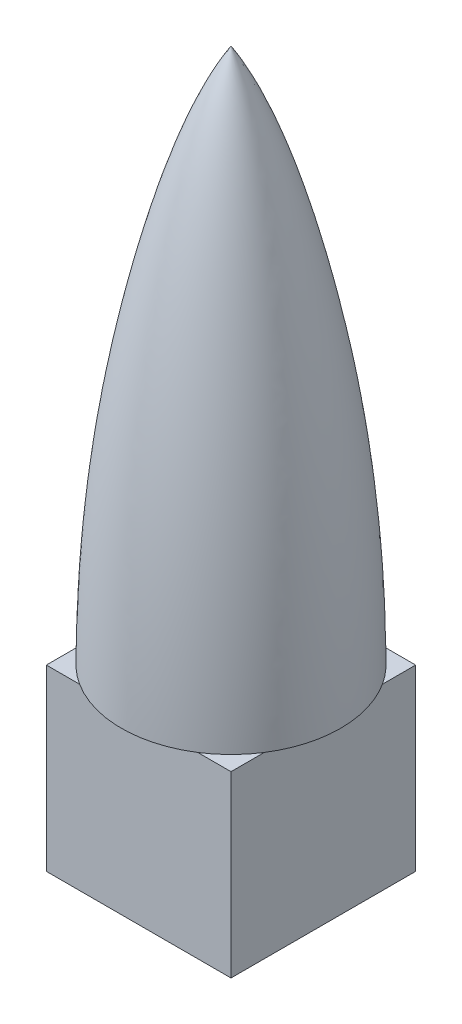
from build123d import *

# Parameters (mm, degrees)
SKETCH1_W           = 15.5
SKETCH1_H           = 15.5
BOSS_EXTRUDE1_DEPTH = 15


with BuildPart() as part:
    # Sketch1 → Boss-Extrude1 (new body)
    with BuildSketch(Plane(origin=(0, 0, 0), x_dir=(1, 0, 0), z_dir=(0, 1, 0))):
        Rectangle(SKETCH1_W, SKETCH1_H)
    extrude(amount=BOSS_EXTRUDE1_DEPTH)

    # Sketch4 → Revolve5 (revolve)
    with BuildSketch(Plane.XY):
        with BuildLine():
            Line((9.2, 15), (0, 15))
            Line((0, 15), (0, 60))
            add(Edge.make_bspline(
                [(9.2, 15), (9.152248995, 24.690987366), (8.00981737, 34.882517262), (4.24723587, 50.506815958), (2.016778071, 56.805895624), (0, 60)],
                knots=[0, 0, 0, 0, 0.565414982, 0.665414982, 1, 1, 1, 1], degree=3))
        make_face()
    revolve(axis=Axis((0, 15, 0), (0, 1, 0)))


solid = part.part
